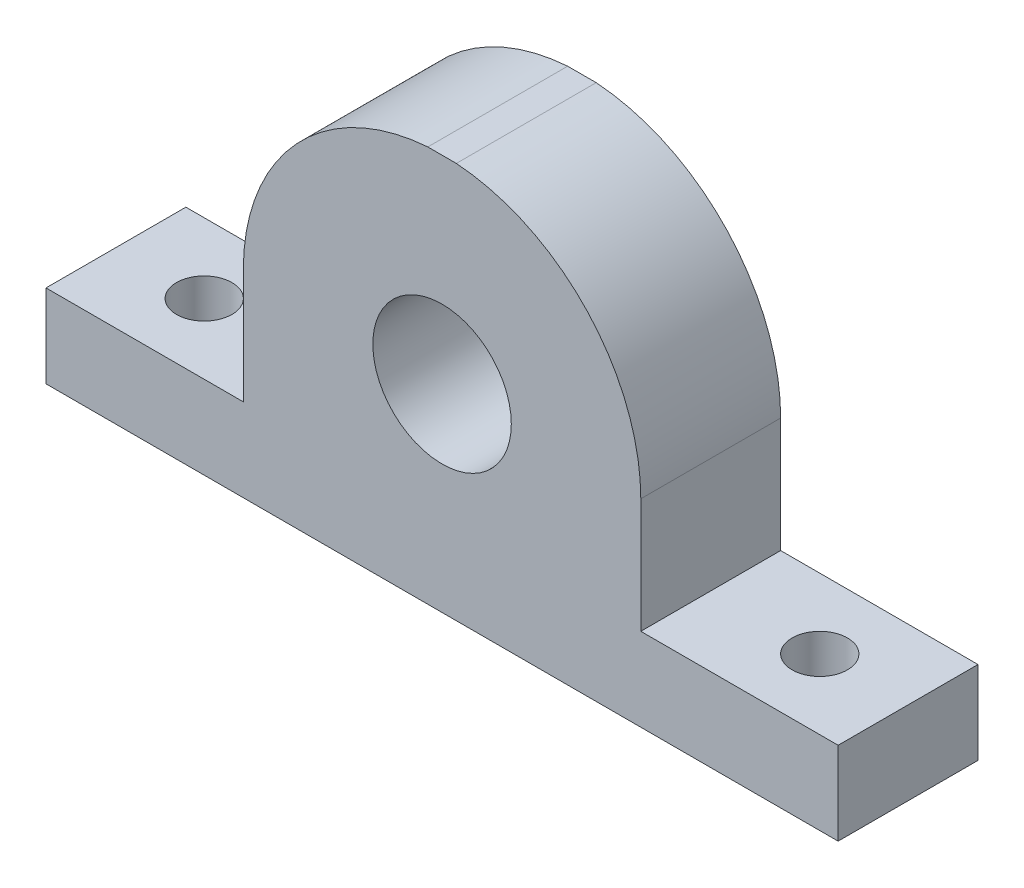
from build123d import *

# Parameters (mm, degrees)
SKETCH1_W               = 57.2
SKETCH1_H               = 28.6
BOSS_EXTRUDE1_DEPTH     = 10.1
SKETCH3_R               = 5
CUT_EXTRUDE2_DEPTH      = 11.1
CUT_EXTRUDE3_DEPTH      = 1
CUT_EXTRUDE3_DEPTH_BACK = 11.1
SKETCH5_R               = 2
CUT_EXTRUDE4_DEPTH      = 6.999141562


with BuildPart() as part:
    # Sketch1 → Boss-Extrude1 (new body)
    with BuildSketch(Plane.XY):
        with Locations((28.6, 14.3)):
            Rectangle(SKETCH1_W, SKETCH1_H)
    extrude(amount=BOSS_EXTRUDE1_DEPTH)

    # Sketch3 → Cut-Extrude2 (cut, through all)
    with BuildSketch(Plane.XY.offset(10.1)):
        with Locations((28.6, 14.287)):
            Circle(SKETCH3_R)
    extrude(amount=-CUT_EXTRUDE2_DEPTH, mode=Mode.SUBTRACT)

    # Sketch4 → Cut-Extrude3 (cut, two sides)
    with BuildSketch(Plane.XY.offset(10.1)) as cut_extrude3_sk:
        with BuildLine():
            Line((-133.041822115, 5.999141562), (0, 5.999141562))
            Line((0, 5.999141562), (14.25, 5.999141562))
            Line((14.25, 5.999141562), (14.25, 14.287))
            ThreePointArc((14.25, 14.287), (28.6, 28.637), (42.95, 14.287))
            Line((42.95, 14.287), (42.95, 5.999141562))
            Line((42.95, 5.999141562), (57.219085061, 5.999141562))
            Line((57.219085061, 5.999141562), (190.260907176, 5.999141562))
            Line((190.260907176, 5.999141562), (190.260907176, 272.082785792))
            Line((190.260907176, 272.082785792), (-133.041822115, 272.082785792))
            Line((-133.041822115, 272.082785792), (-133.041822115, 5.999141562))
        make_face()
    extrude(amount=CUT_EXTRUDE3_DEPTH, mode=Mode.SUBTRACT)
    extrude(cut_extrude3_sk.sketch, amount=-CUT_EXTRUDE3_DEPTH_BACK, mode=Mode.SUBTRACT)

    # Sketch5 → Cut-Extrude4 (cut, through all)
    with BuildSketch(Plane(origin=(0, 5.999141562, 0), x_dir=(-1, 0, 0), z_dir=(0, 1, 0))):
        with Locations((-6.375, 5.05)):
            Circle(SKETCH5_R)
        with Locations((-50.825, 5.05)):
            Circle(SKETCH5_R)
    extrude(amount=-CUT_EXTRUDE4_DEPTH, mode=Mode.SUBTRACT)


solid = part.part
